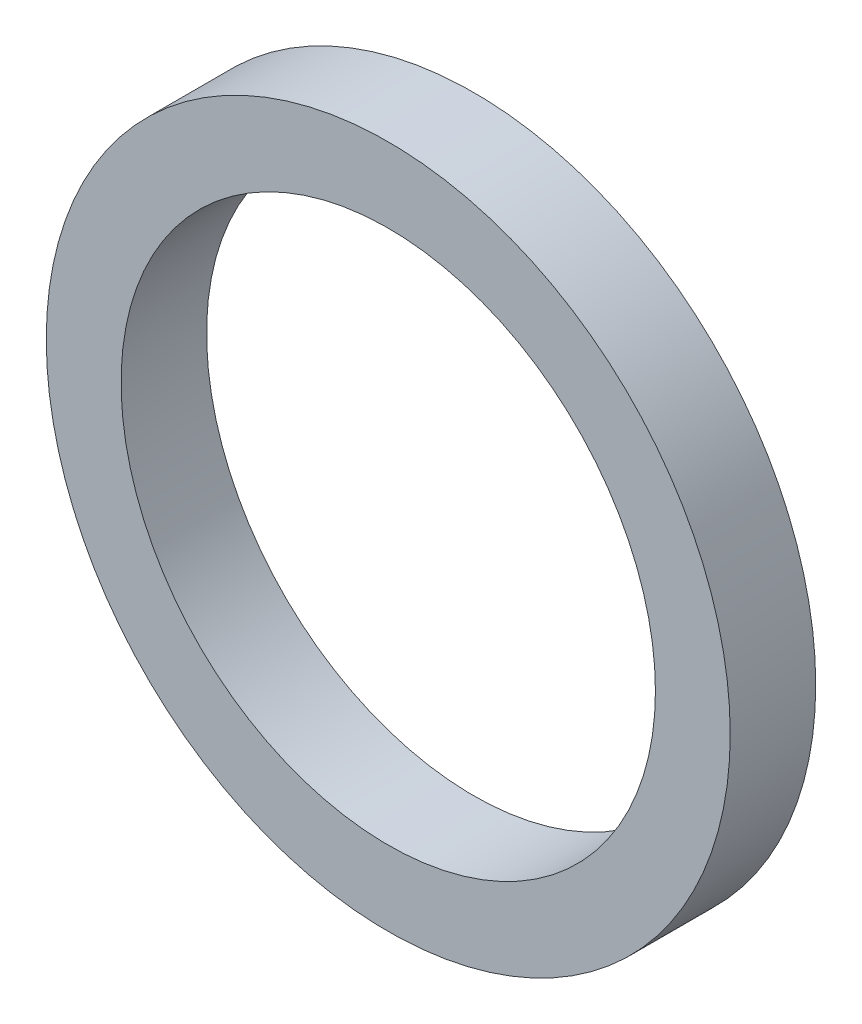
from build123d import *

# Parameters (mm, degrees)
SKETCH_1_R      = 16
SKETCH_1_R_2    = 12.5
EXTRUDE_1_DEPTH = 4


with BuildPart() as part:
    # 草图1 → 凸台-拉伸1 (new body)
    with BuildSketch(Plane.XY):
        Circle(SKETCH_1_R)
        Circle(SKETCH_1_R_2, mode=Mode.SUBTRACT)
    extrude(amount=EXTRUDE_1_DEPTH)


solid = part.part
